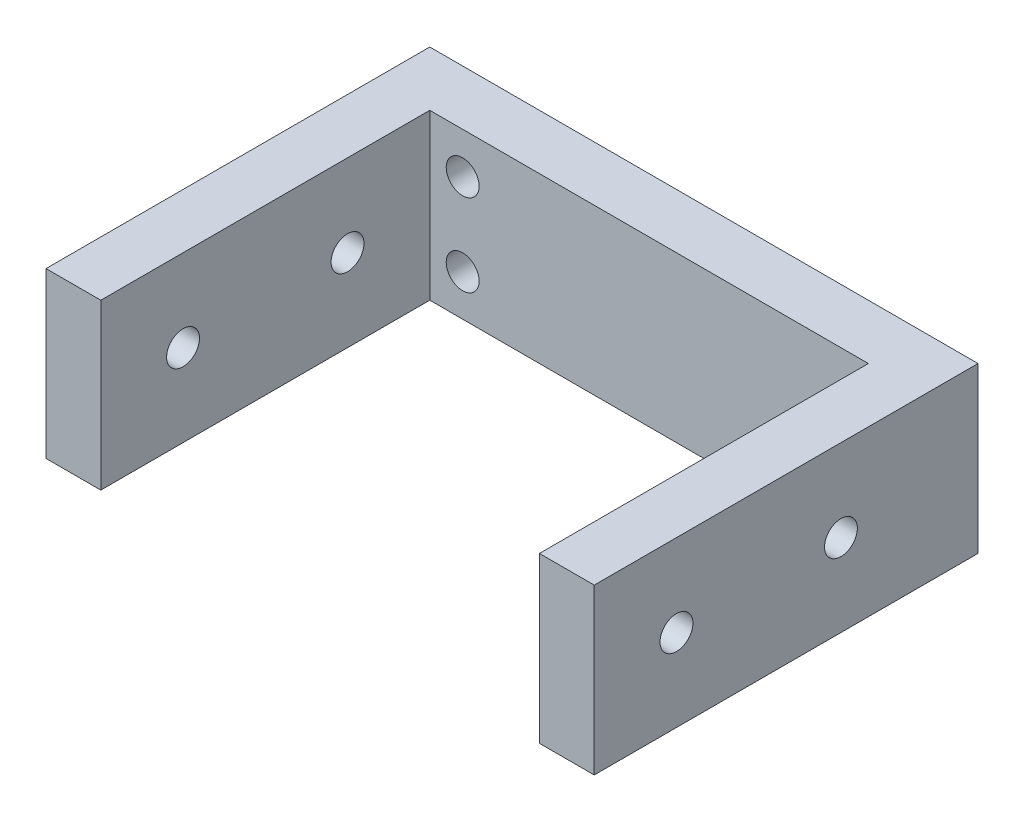
from build123d import *

# Parameters (mm, degrees)
BOSS_EXTRUDE1_DEPTH      = 2.5
BOSS_EXTRUDE1_DEPTH_BACK = 2.5
SKETCH1_W                = 50
SKETCH1_H                = 15
SKETCH2_W                = 5
SKETCH2_H                = 15
BOSS_EXTRUDE2_DEPTH      = 30
SKETCH3_W                = 5
SKETCH3_H                = 15
BOSS_EXTRUDE3_DEPTH      = 30
SKETCH4_R                = 1.5
CUT_EXTRUDE1_DEPTH       = 5
SKETCH5_R                = 1.5
CUT_EXTRUDE2_DEPTH       = 5
CUT_EXTRUDE3_START       = -5
SKETCH6_R                = 1.5
CUT_EXTRUDE3_DEPTH       = 5
CUT_EXTRUDE5_START       = -5
SKETCH7_R                = 1.5
CUT_EXTRUDE5_DEPTH       = 5
SKETCH11_R               = 1.5
CUT_EXTRUDE6_DEPTH       = 5
SKETCH12_R               = 1.5
CUT_EXTRUDE7_DEPTH       = 5


with BuildPart() as part:
    # Sketch1 → Boss-Extrude1 (new, two sides: drawn at the far end of the back side and taken through both)
    with BuildSketch(Plane.XY.offset(-BOSS_EXTRUDE1_DEPTH_BACK)):
        with Locations((-24.404028235, -7.321208471)):
            Rectangle(SKETCH1_W, SKETCH1_H)
    extrude(amount=BOSS_EXTRUDE1_DEPTH + BOSS_EXTRUDE1_DEPTH_BACK)

    # Sketch2 → Boss-Extrude2 (add)
    with BuildSketch(Plane.XY.offset(2.5)):
        with Locations((-46.904028235, -7.321208471)):
            Rectangle(SKETCH2_W, SKETCH2_H)
    extrude(amount=BOSS_EXTRUDE2_DEPTH)

    # Sketch3 → Boss-Extrude3 (add)
    with BuildSketch(Plane.XY.offset(2.5)):
        with Locations((-1.904028235, -7.321208471)):
            Rectangle(SKETCH3_W, SKETCH3_H)
    extrude(amount=BOSS_EXTRUDE3_DEPTH)

    # Sketch4 → Cut-Extrude1 (cut)
    with BuildSketch(Plane.ZY.offset(49.404028235)):
        with Locations((25, -7.321208471)):
            Circle(SKETCH4_R)
    extrude(amount=-CUT_EXTRUDE1_DEPTH, mode=Mode.SUBTRACT)

    # Sketch5 → Cut-Extrude2 (cut)
    with BuildSketch(Plane.ZY.offset(49.404028235)):
        with Locations((10, -7.321208471)):
            Circle(SKETCH5_R)
    extrude(amount=-CUT_EXTRUDE2_DEPTH, mode=Mode.SUBTRACT)

    # Sketch6 → Cut-Extrude3 (cut)
    with BuildSketch(Plane(origin=(0.595971765, 0, 0), x_dir=(0, 0, -1), z_dir=(1, 0, 0)).offset(CUT_EXTRUDE3_START)):
        with Locations((-25, -7.321208471)):
            Circle(SKETCH6_R)
    extrude(amount=CUT_EXTRUDE3_DEPTH, mode=Mode.SUBTRACT)

    # Sketch7 → Cut-Extrude5 (cut)
    with BuildSketch(Plane(origin=(0.595971765, 0, 0), x_dir=(0, 0, -1), z_dir=(1, 0, 0)).offset(CUT_EXTRUDE5_START)):
        with Locations((-10, -7.321208471)):
            Circle(SKETCH7_R)
    extrude(amount=CUT_EXTRUDE5_DEPTH, mode=Mode.SUBTRACT)

    # Sketch11 → Cut-Extrude6 (cut)
    with BuildSketch(Plane(origin=(0, 0, -2.5), x_dir=(-1, 0, 0), z_dir=(0, 0, -1))):
        with Locations((41.404028235, -3.571208471)):
            Circle(SKETCH11_R)
        with Locations((41.404028235, -11.071208471)):
            Circle(SKETCH11_R)
    extrude(amount=-CUT_EXTRUDE6_DEPTH, mode=Mode.SUBTRACT)

    # Sketch12 → Cut-Extrude7 (cut)
    with BuildSketch(Plane(origin=(0, 0, -2.5), x_dir=(-1, 0, 0), z_dir=(0, 0, -1))):
        with Locations((6.404028235, -7.321208471)):
            Circle(SKETCH12_R)
    extrude(amount=-CUT_EXTRUDE7_DEPTH, mode=Mode.SUBTRACT)


solid = part.part
